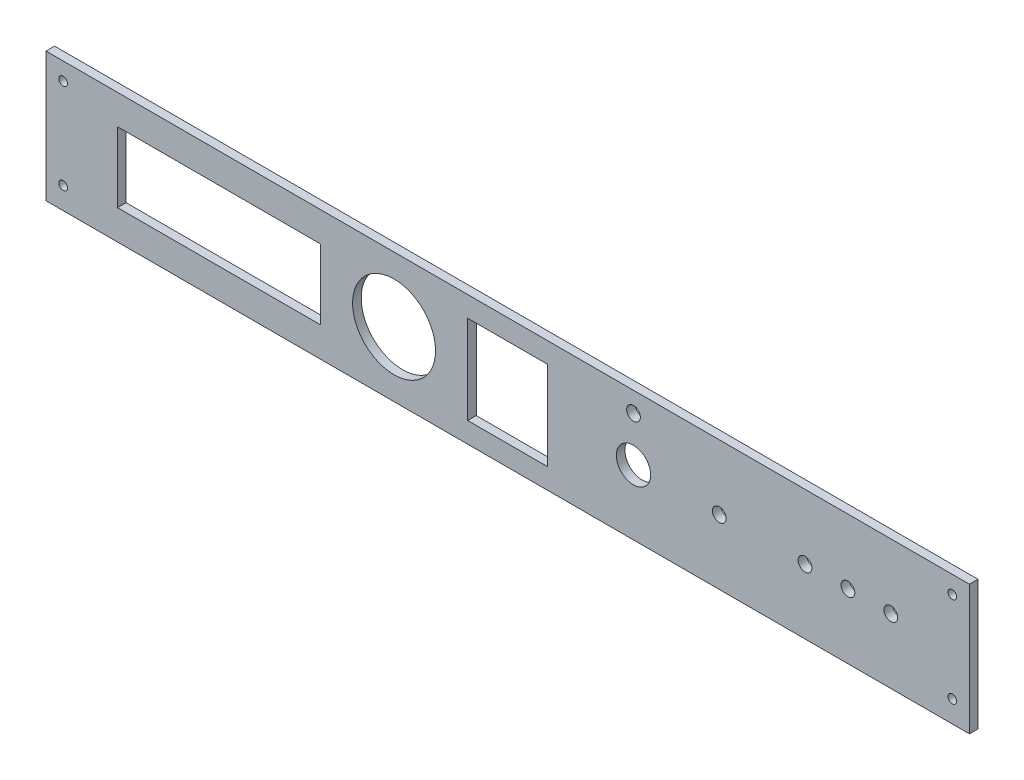
from build123d import *

# Parameters (mm, degrees)
SKETCH1_W               = 323
SKETCH1_H               = 45.34
BOSS_EXTRUDE1_DEPTH     = 3
SKETCH2_R               = 6
SKETCH2_R_2             = 2.4
SKETCH2_R_3             = 14.5
SKETCH2_R_4             = 1.5
SKETCH2_W               = 71
SKETCH2_H               = 24.5
SKETCH2_W_2             = 28
SKETCH2_H_2             = 31
CUT_EXTRUDE1_DEPTH      = 1
CUT_EXTRUDE1_DEPTH_BACK = 4


with BuildPart() as part:
    # Sketch1 → Boss-Extrude1 (new body)
    with BuildSketch(Plane.XY):
        Rectangle(SKETCH1_W, SKETCH1_H)
    extrude(amount=BOSS_EXTRUDE1_DEPTH)

    # Sketch2 → Cut-Extrude1 (cut, two sides)
    with BuildSketch(Plane.XY.offset(3)) as cut_extrude1_sk:
        with Locations((44, 0)):
            Circle(SKETCH2_R)
        with Locations((74, 0)):
            Circle(SKETCH2_R_2)
        with Locations((44, 15.67)):
            Circle(SKETCH2_R_2)
        with Locations((134, 0)):
            Circle(SKETCH2_R_2)
        with Locations((119, 0)):
            Circle(SKETCH2_R_2)
        with Locations((104, 0)):
            Circle(SKETCH2_R_2)
        with Locations((-39.75, 0)):
            Circle(SKETCH2_R_3)
        with Locations((-155.5, 16.55)):
            Circle(SKETCH2_R_4)
        with Locations((-155.5, -15.05)):
            Circle(SKETCH2_R_4)
        with Locations((155.5, -15.05)):
            Circle(SKETCH2_R_4)
        with Locations((155.5, 16.55)):
            Circle(SKETCH2_R_4)
        with Locations((-101, 0)):
            Rectangle(SKETCH2_W, SKETCH2_H)
        Rectangle(SKETCH2_W_2, SKETCH2_H_2)
    extrude(amount=CUT_EXTRUDE1_DEPTH, mode=Mode.SUBTRACT)
    extrude(cut_extrude1_sk.sketch, amount=-CUT_EXTRUDE1_DEPTH_BACK, mode=Mode.SUBTRACT)


solid = part.part
